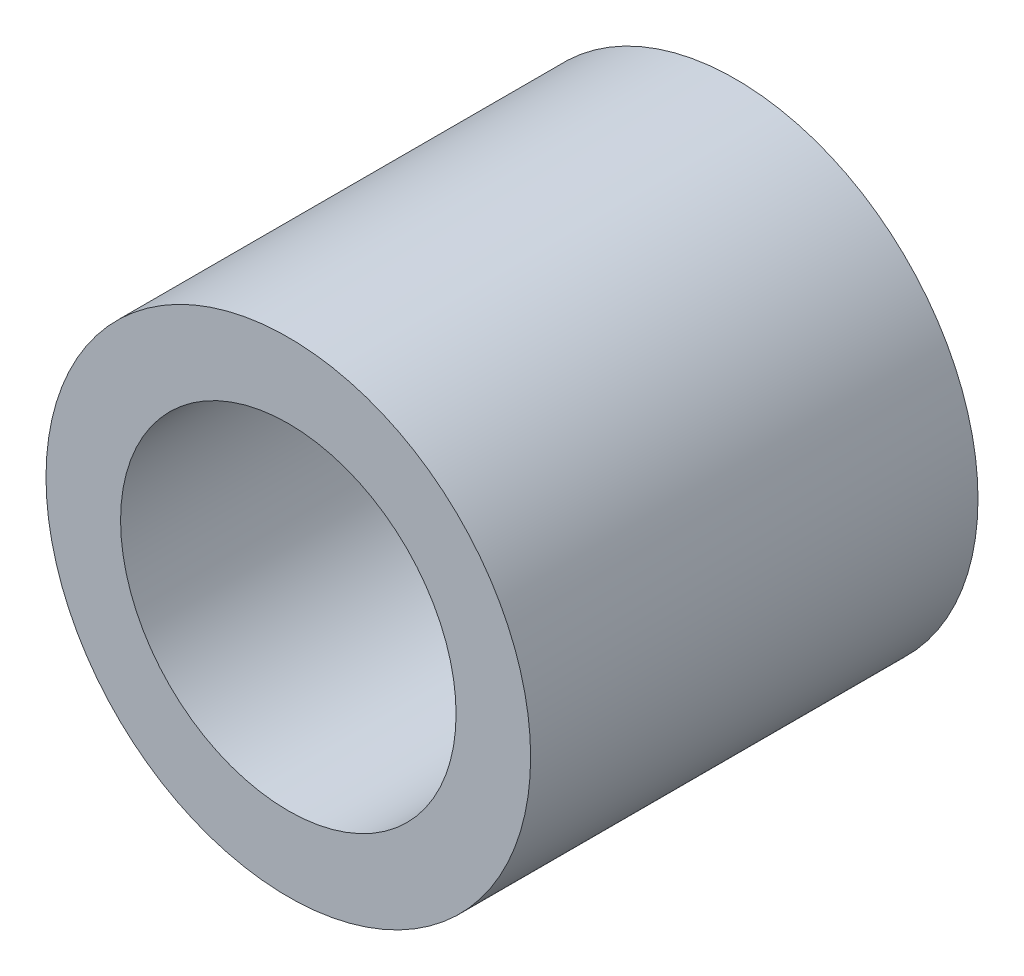
from build123d import *

# Parameters (mm, degrees)
SKETCH1_R           = 3.25
SKETCH1_R_2         = 2.25
BOSS_EXTRUDE1_DEPTH = 6


with BuildPart() as part:
    # Sketch1 → Boss-Extrude1 (new body)
    with BuildSketch(Plane.XY):
        Circle(SKETCH1_R)
        Circle(SKETCH1_R_2, mode=Mode.SUBTRACT)
    extrude(amount=BOSS_EXTRUDE1_DEPTH)


solid = part.part
